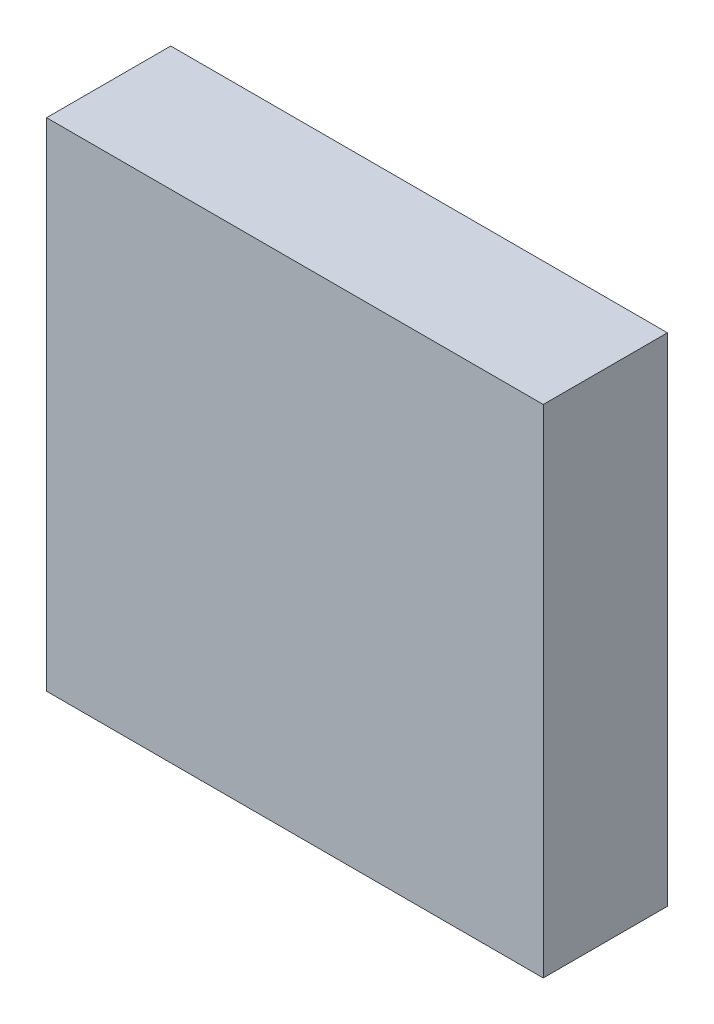
from build123d import *

# Parameters (mm, degrees)
CROQUIS1_W              = 40
CROQUIS1_H              = 40
SALIENTE_EXTRUIR1_DEPTH = 10


with BuildPart() as part:
    # Croquis1 → Saliente-Extruir1 (new body)
    with BuildSketch(Plane.XY):
        Rectangle(CROQUIS1_W, CROQUIS1_H)
    extrude(amount=SALIENTE_EXTRUIR1_DEPTH)


solid = part.part
